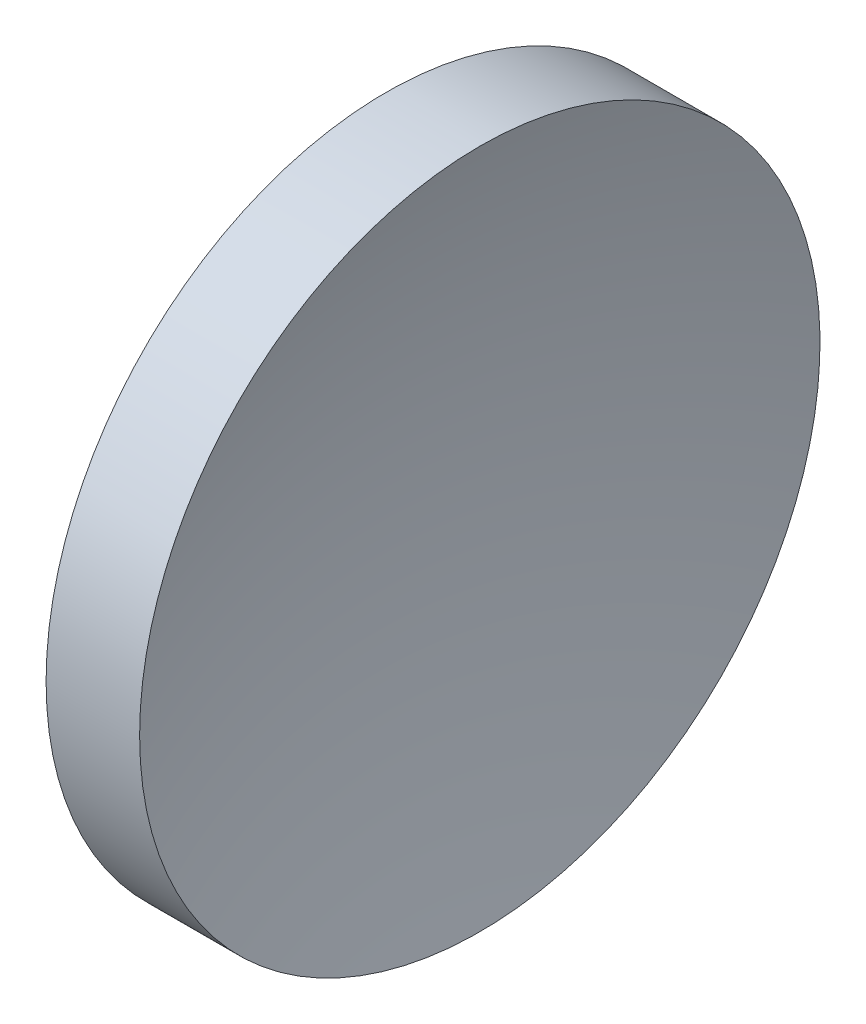
from build123d import *


with BuildPart() as part:
    # 草图1 → 旋转1 (revolve)
    with BuildSketch(Plane.XY):
        with BuildLine():
            Line((113.739437135, 65.155630457), (113.739437135, 90.155630457))
            Line((113.739437135, 90.155630457), (120.612599738, 90.155630457))
            ThreePointArc((120.612599738, 90.155630457), (117.713469366, 77.80475482), (116.739437135, 65.155630457))
            Line((116.739437135, 65.155630457), (113.739437135, 65.155630457))
        make_face()
    revolve(axis=Axis((105.621837124, 65.155630457, 0), (1, 0, 0)))


solid = part.part
